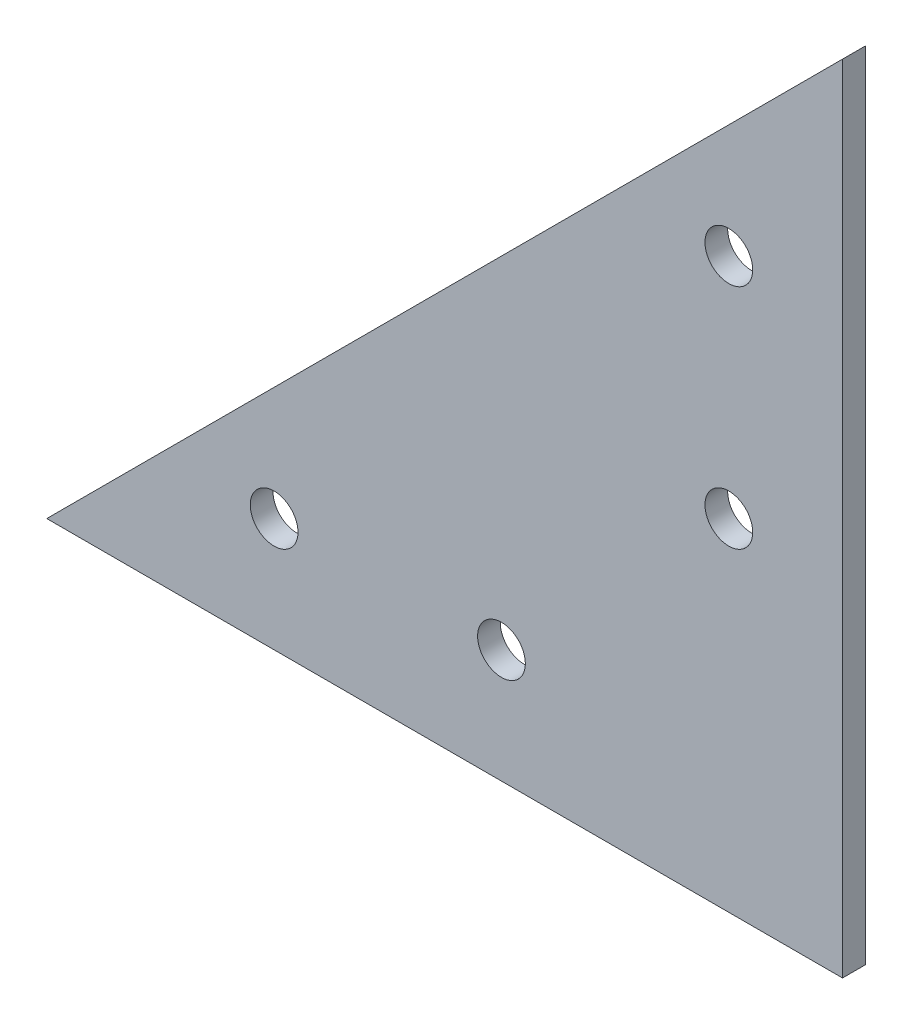
from build123d import *

# Parameters (mm, degrees)
SKETCH_1_R      = 2.1
EXTRUDE_1_DEPTH = 2


with BuildPart() as part:
    # ｽｹｯﾁ1 → ﾎﾞｽ - 押し出し1 (new body)
    with BuildSketch(Plane.XY):
        Polygon((0, 0), (0, 70), (-70, 0), align=None)
        with Locations((-50, 10)):
            Circle(SKETCH_1_R, mode=Mode.SUBTRACT)
        with BuildLine():
            ThreePointArc((-27.9, 10), (-30, 7.9), (-32.1, 10))
            ThreePointArc((-32.1, 10), (-30, 12.1), (-27.9, 10))
        make_face(mode=Mode.SUBTRACT)
        with BuildLine():
            ThreePointArc((-10, 32.1), (-7.9, 30), (-10, 27.9))
            ThreePointArc((-10, 27.9), (-12.1, 30), (-10, 32.1))
        make_face(mode=Mode.SUBTRACT)
        with Locations((-10, 50)):
            Circle(SKETCH_1_R, mode=Mode.SUBTRACT)
    extrude(amount=EXTRUDE_1_DEPTH)


solid = part.part
